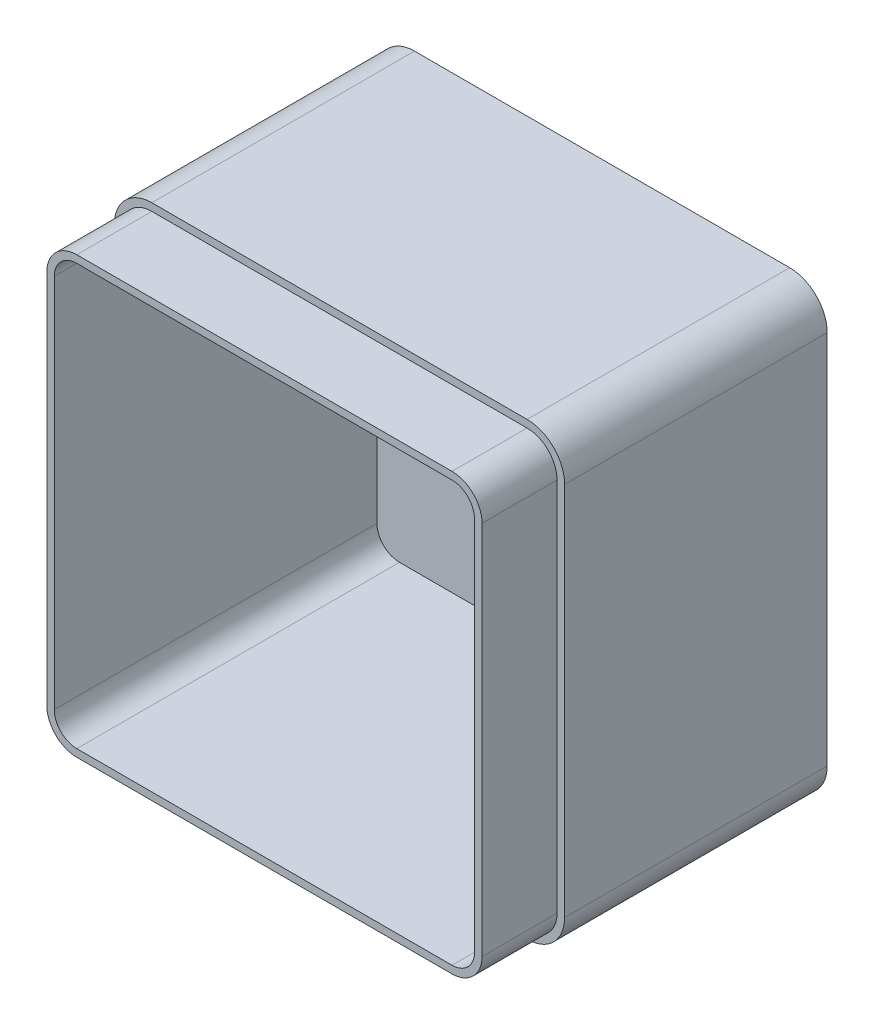
from build123d import *
from build123d.topology import SkipClean

# Parameters (mm, degrees)
SKETCH1_W           = 120
SKETCH1_H           = 120
BOSS_EXTRUDE2_DEPTH = 70
FILLET2_R           = 10
SHELL2_T            = -4
BOSS_EXTRUDE3_DEPTH = 20
CUT_EXTRUDE2_DEPTH  = 40


with BuildPart() as part:
    # Sketch1 → Boss-Extrude2 (new body)
    with BuildSketch(Plane.XY):
        with Locations((-60, 60)):
            Rectangle(SKETCH1_W, SKETCH1_H)
    extrude(amount=BOSS_EXTRUDE2_DEPTH)

    # Fillet2
    fillet2_edges = [part.edges().sort_by_distance(p)[0] for p in [
        (0, 120, 35),
        (0, 0, 35),
        (-120, 0, 35),
        (-120, 120, 35),
    ]]
    fillet(fillet2_edges, radius=FILLET2_R)

    # Shell2
    shell2_openings = [part.faces().sort_by_distance(p)[0] for p in [
        (-60, 60, 70),
    ]]
    offset(amount=SHELL2_T, openings=shell2_openings, kind=Kind.INTERSECTION)

    # 3DSketch3 → Boss-Extrude3 (add)
    with BuildSketch(Plane(origin=(-2, 10, 70), x_dir=(-0.7574099616005767, 0.6529396220694628, 0), z_dir=(0, 0, -1))):
        with BuildLine():
            Line((0, 0), (65.293962207, 75.74099616))
            ThreePointArc((65.293962207, 75.74099616), (70.762268416, 78.495621219), (76.576758876, 76.576758876))
            Line((76.576758876, 76.576758876), (152.317755036, 11.282796669))
            ThreePointArc((152.317755036, 11.282796669), (155.072380095, 5.814490461), (153.153517753, 0))
            Line((153.153517753, 0), (87.859555546, -75.74099616))
            ThreePointArc((87.859555546, -75.74099616), (82.391249337, -78.495621219), (76.576758876, -76.576758876))
            Line((76.576758876, -76.576758876), (0.835762716, -11.282796669))
            ThreePointArc((0.835762716, -11.282796669), (-1.918862343, -5.814490461), (0, 0))
        make_face()
    extrude(amount=-BOSS_EXTRUDE3_DEPTH)

    # 3DSketch4 → Cut-Extrude2 (cut)
    with SkipClean():  # the faces are left unmerged after this step: merging them gives an invalid solid
        with BuildSketch(Plane(origin=(-4, 10, 90), x_dir=(-0.7459376616259146, 0.6660157693088524, 0), z_dir=(0, 0, -1))):
            with BuildLine():
                Line((0, 0), (66.601576931, 74.593766163))
                ThreePointArc((66.601576931, 74.593766163), (70.738123029, 76.588082621), (75.073297516, 75.073297516))
                Line((75.073297516, 75.073297516), (149.667063679, 8.471720586))
                ThreePointArc((149.667063679, 8.471720586), (151.661380138, 4.335174488), (150.146595033, 0))
                Line((150.146595033, 0), (83.545018102, -74.593766163))
                ThreePointArc((83.545018102, -74.593766163), (79.408472004, -76.588082621), (75.073297516, -75.073297516))
                Line((75.073297516, -75.073297516), (0.479531354, -8.471720586))
                ThreePointArc((0.479531354, -8.471720586), (-1.514785105, -4.335174488), (0, 0))
            make_face()
        extrude(amount=CUT_EXTRUDE2_DEPTH, mode=Mode.SUBTRACT)


solid = part.part
